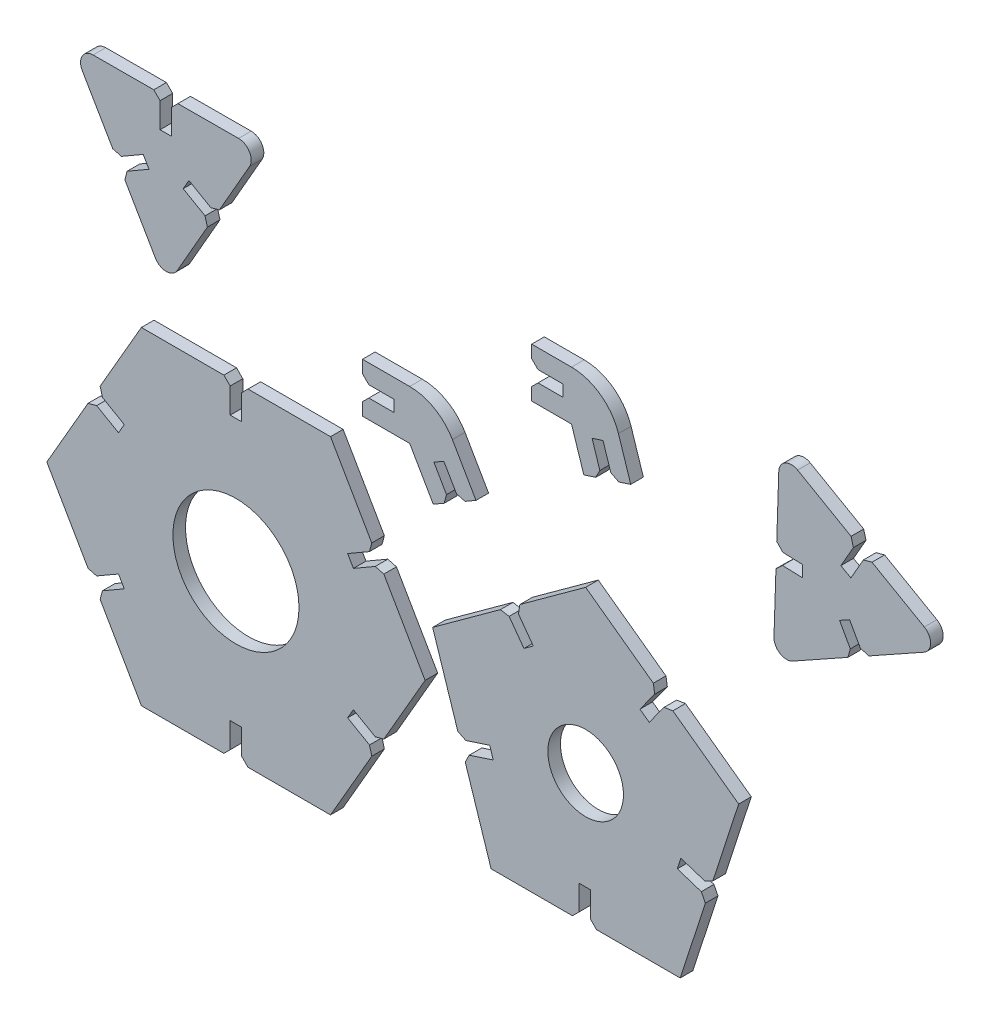
from build123d import *

# Parameters (mm, degrees)
SALIENTE_EXTRUIR1_DEPTH = 4
CHAFL_N1_SIZE           = 2
SALIENTE_EXTRUIR2_DEPTH = 4
CHAFL_N2_SIZE           = 2
SALIENTE_EXTRUIR3_DEPTH = 4
CHAFL_N3_SIZE           = 2
REDONDEO1_R             = 15.65
SALIENTE_EXTRUIR4_DEPTH = 4
REDONDEO2_R             = 15.65
CHAFL_N4_SIZE           = 2
CROQUIS5_R              = 20
CROQUIS5_R_2            = 12
CORTAR_EXTRUIR1_DEPTH   = 4
SALIENTE_EXTRUIR6_DEPTH = 4
REDONDEO4_R             = 4
SALIENTE_EXTRUIR7_DEPTH = 4
REDONDEO5_R             = 4
CHAFL_N5_SIZE           = 2
CHAFL_N5_SIZE2          = 1.993496113
CHAFL_N5_EDGE_2_SIZE    = 2
CHAFL_N5_EDGE_2_SIZE2   = 2.006567963
CHAFL_N5_EDGE_3_SIZE    = 1.993496113
CHAFL_N5_EDGE_3_SIZE2   = 2
CHAFL_N5_EDGE_4_SIZE    = 2.006567963
CHAFL_N5_EDGE_4_SIZE2   = 2
CHAFL_N5_EDGE_5_SIZE    = 1.993496113
CHAFL_N5_EDGE_5_SIZE2   = 2
CHAFL_N5_EDGE_6_SIZE    = 2
CHAFL_N5_EDGE_6_SIZE2   = 2.006567963
CHAFL_N6_SIZE           = 2


with BuildPart() as part:
    # Croquis1 → Saliente-Extruir1 (new body)
    with BuildSketch(Plane.XY):
        Polygon((-22.498762614, 34.692740635), (-16.620910091, 26.602570691), (-19.57382212, 24.45715452), (-25.451674643, 32.547324464), (-48.541019662, 15.771933364), (-39.947257049, -10.676948355), (-30.436691886, -7.586778411), (-29.308779857, -11.058134695), (-38.819345019, -14.148304639), (-30, -41.291457614), (-2.19, -41.291457614), (-2.19, -31.291457614), (1.46, -31.291457614), (1.46, -41.291457614), (30, -41.291457614), (38.593762614, -14.842575896), (29.083197451, -11.752405952), (30.21110948, -8.281049668), (39.721674643, -11.371219611), (48.541019662, 15.771933364), (26.042257049, 32.11824123), (20.164404526, 24.028071286), (17.211492497, 26.173487457), (23.089345019, 34.263657401), (0, 51.039048501), align=None)
    extrude(amount=SALIENTE_EXTRUIR1_DEPTH)

    # Chaflán1
    chafl_n1_edges = [part.edges().sort_by_distance(p)[0] for p in [
        (23.089345019, 34.263657401, 2),
        (26.042257049, 32.11824123, 2),
        (39.721674643, -11.371219611, 2),
        (38.593762614, -14.842575896, 2),
        (1.46, -41.291457614, 2),
        (-2.19, -41.291457614, 2),
        (-38.819345019, -14.148304639, 2),
        (-39.947257049, -10.676948355, 2),
        (-25.451674643, 32.547324464, 2),
        (-22.498762614, 34.692740635, 2),
    ]]
    chamfer(chafl_n1_edges, length=CHAFL_N1_SIZE)


with BuildPart() as body_2:
    # Croquis2 → Saliente-Extruir2 (new body)
    with BuildSketch(Plane.XY):
        Polygon((-50.935771969, 0), (-65.023271969, 24.400265752), (-73.683526006, 19.400265752), (-75.508526006, 22.561258475), (-66.848271969, 27.561258475), (-80.935771969, 51.961524227), (-109.110771969, 51.961524227), (-109.110771969, 41.961524227), (-112.760771969, 41.961524227), (-112.760771969, 51.961524227), (-140.935771969, 51.961524227), (-155.023271969, 27.561258475), (-146.363017931, 22.561258475), (-148.188017931, 19.400265752), (-156.848271969, 24.400265752), (-170.935771969, 0), (-156.848271969, -24.400265752), (-148.188017931, -19.400265752), (-146.363017931, -22.561258475), (-155.023271969, -27.561258475), (-140.935771969, -51.961524227), (-112.760771969, -51.961524227), (-112.760771969, -41.961524227), (-109.110771969, -41.961524227), (-109.110771969, -51.961524227), (-80.935771969, -51.961524227), (-66.848271969, -27.561258475), (-75.508526006, -22.561258475), (-73.683526006, -19.400265752), (-65.023271969, -24.400265752), align=None)
    extrude(amount=SALIENTE_EXTRUIR2_DEPTH)

    # Chaflán2
    chafl_n2_edges = [body_2.edges().sort_by_distance(p)[0] for p in [
        (-65.023271969, -24.400265752, 2),
        (-66.848271969, -27.561258475, 2),
        (-109.110771969, -51.961524227, 2),
        (-112.760771969, -51.961524227, 2),
        (-155.023271969, -27.561258475, 2),
        (-156.848271969, -24.400265752, 2),
        (-156.848271969, 24.400265752, 2),
        (-155.023271969, 27.561258475, 2),
        (-112.760771969, 51.961524227, 2),
        (-109.110771969, 51.961524227, 2),
        (-66.848271969, 27.561258475, 2),
        (-65.023271969, 24.400265752, 2),
    ]]
    chamfer(chafl_n2_edges, length=CHAFL_N2_SIZE)


with BuildPart() as body_3:
    # Croquis3 → Saliente-Extruir3 (new body)
    with BuildSketch(Plane.XY):
        Polygon((-70.786284867, 78.305161206), (-46.786284867, 78.305161206), (-34.786284867, 57.520551515), (-39.98243729, 54.520551515), (-44.98243729, 63.180805553), (-48.143430014, 61.355805553), (-43.143430014, 52.695551515), (-48.339582437, 49.695551515), (-55.82181658, 62.655161206), (-70.786284867, 62.655161206), (-70.786284867, 68.655161206), (-60.786284867, 68.655161206), (-60.786284867, 72.305161206), (-70.786284867, 72.305161206), align=None)
    extrude(amount=SALIENTE_EXTRUIR3_DEPTH)

    # Chaflán3
    chafl_n3_edges = [body_3.edges().sort_by_distance(p)[0] for p in [
        (-39.98243729, 54.520551515, 2),
        (-43.143430014, 52.695551515, 2),
        (-70.786284867, 68.655161206, 2),
        (-70.786284867, 72.305161206, 2),
    ]]
    chamfer(chafl_n3_edges, length=CHAFL_N3_SIZE)

    # Redondeo1
    redondeo1_edges = [body_3.edges().sort_by_distance(p)[0] for p in [
        (-46.786284867, 78.305161206, 2),
    ]]
    fillet(redondeo1_edges, radius=REDONDEO1_R)


with BuildPart() as body_4:
    # Croquis4 → Saliente-Extruir4 (new body)
    with BuildSketch(Plane.XY):
        Polygon((-17.115231159, 109.292158512), (6.884768841, 109.292158512), (14.301176706, 86.466802121), (8.594837608, 84.612700155), (5.504667664, 94.123265318), (2.03331138, 92.995353288), (5.123481324, 83.484788125), (-0.582857774, 81.630686159), (-4.485621722, 93.642158512), (-17.115231159, 93.642158512), (-17.115231159, 99.642158512), (-7.115231159, 99.642158512), (-7.115231159, 103.292158512), (-17.115231159, 103.292158512), align=None)
    extrude(amount=SALIENTE_EXTRUIR4_DEPTH)

    # Redondeo2
    redondeo2_edges = [body_4.edges().sort_by_distance(p)[0] for p in [
        (6.884768841, 109.292158512, 2),
    ]]
    fillet(redondeo2_edges, radius=REDONDEO2_R)

    # Chaflán4
    chafl_n4_edges = [body_4.edges().sort_by_distance(p)[0] for p in [
        (8.594837608, 84.612700155, 2),
        (5.123481324, 83.484788125, 2),
        (-17.115231159, 99.642158512, 2),
        (-17.115231159, 103.292158512, 2),
    ]]
    chamfer(chafl_n4_edges, length=CHAFL_N4_SIZE)


with BuildPart() as cortar_extruir1_tool:
    # Croquis5 → Cortar-Extruir1 (new body)
    with BuildSketch(Plane.XY.offset(4)):
        with Locations((-110.935771969, 0)):
            Circle(CROQUIS5_R)
        Circle(CROQUIS5_R_2)
    extrude(amount=-CORTAR_EXTRUIR1_DEPTH)


with BuildPart() as part_1:
    add(part.part)

    # Cortar-Extruir1: cut by cortar_extruir1_tool
    add(cortar_extruir1_tool.part, mode=Mode.SUBTRACT)


with BuildPart() as body_2_1:
    add(body_2.part)

    # Cortar-Extruir1: cut by cortar_extruir1_tool
    add(cortar_extruir1_tool.part, mode=Mode.SUBTRACT)


with BuildPart() as body_5:
    # Croquis8 → Saliente-Extruir6 (new body)
    with BuildSketch(Plane.XY):
        Polygon((-163.180597318, 119.138873384), (-149.013359447, 94.784644314), (-140.353105409, 99.784644314), (-138.528105409, 96.62365159), (-147.178029607, 91.629615526), (-133.010791736, 67.275386456), (-119.003029607, 91.721688889), (-127.663283645, 96.721688889), (-125.838283645, 99.882681613), (-117.188359447, 94.888645548), (-103.180597318, 119.334947981), (-131.355597318, 119.242874618), (-131.355597318, 109.242874618), (-135.005597318, 109.242874618), (-135.005597318, 119.230946747), align=None)
    extrude(amount=SALIENTE_EXTRUIR6_DEPTH)

    # Redondeo4
    redondeo4_edges = [body_5.edges().sort_by_distance(p)[0] for p in [
        (-163.180597318, 119.138873384, 2),
        (-103.180597318, 119.334947981, 2),
        (-133.010791736, 67.275386456, 2),
    ]]
    fillet(redondeo4_edges, radius=REDONDEO4_R)

    # Chaflán5
    chafl_n5_edges = [body_5.edges().sort_by_distance(p)[0] for p in [
        (-147.178029607, 91.629615526, 2),
    ]]
    chafl_n5_side = [body_5.faces().sort_by_distance(p)[0] for p in [
        (-142.853067508, 94.126633558, 2),
    ]]
    chamfer(chafl_n5_edges, length=CHAFL_N5_SIZE, length2=CHAFL_N5_SIZE2, reference=chafl_n5_side[0])

    # Chaflán5 edge 2
    chafl_n5_edge_2_edges = [body_5.edges().sort_by_distance(p)[0] for p in [
        (-149.013359447, 94.784644314, 2),
    ]]
    chafl_n5_edge_2_side = [body_5.faces().sort_by_distance(p)[0] for p in [
        (-154.355133146, 103.967435023, 2),
    ]]
    chamfer(chafl_n5_edge_2_edges, length=CHAFL_N5_EDGE_2_SIZE, length2=CHAFL_N5_EDGE_2_SIZE2, reference=chafl_n5_edge_2_side[0])

    # Chaflán5 edge 3
    chafl_n5_edge_3_edges = [body_5.edges().sort_by_distance(p)[0] for p in [
        (-135.005597318, 119.230946747, 2),
    ]]
    chafl_n5_edge_3_side = [body_5.faces().sort_by_distance(p)[0] for p in [
        (-145.6290142, 119.196230377, 2),
    ]]
    chamfer(chafl_n5_edge_3_edges, length=CHAFL_N5_EDGE_3_SIZE, length2=CHAFL_N5_EDGE_3_SIZE2, reference=chafl_n5_edge_3_side[0])

    # Chaflán5 edge 4
    chafl_n5_edge_4_edges = [body_5.edges().sort_by_distance(p)[0] for p in [
        (-131.355597318, 119.242874618, 2),
    ]]
    chafl_n5_edge_4_side = [body_5.faces().sort_by_distance(p)[0] for p in [
        (-131.355597318, 114.242874618, 2),
    ]]
    chamfer(chafl_n5_edge_4_edges, length=CHAFL_N5_EDGE_4_SIZE, length2=CHAFL_N5_EDGE_4_SIZE2, reference=chafl_n5_edge_4_side[0])

    # Chaflán5 edge 5
    chafl_n5_edge_5_edges = [body_5.edges().sort_by_distance(p)[0] for p in [
        (-117.188359447, 94.888645548, 2),
    ]]
    chafl_n5_edge_5_side = [body_5.faces().sort_by_distance(p)[0] for p in [
        (-111.906716264, 104.106152628, 2),
    ]]
    chamfer(chafl_n5_edge_5_edges, length=CHAFL_N5_EDGE_5_SIZE, length2=CHAFL_N5_EDGE_5_SIZE2, reference=chafl_n5_edge_5_side[0])

    # Chaflán5 edge 6
    chafl_n5_edge_6_edges = [body_5.edges().sort_by_distance(p)[0] for p in [
        (-119.003029607, 91.721688889, 2),
    ]]
    chafl_n5_edge_6_side = [body_5.faces().sort_by_distance(p)[0] for p in [
        (-124.28467279, 82.504181809, 2),
    ]]
    chamfer(chafl_n5_edge_6_edges, length=CHAFL_N5_EDGE_6_SIZE, length2=CHAFL_N5_EDGE_6_SIZE2, reference=chafl_n5_edge_6_side[0])


with BuildPart() as body_6:
    # Croquis7 → Saliente-Extruir7 (new body)
    with BuildSketch(Plane.XY):
        Polygon((61.477596493, 120.158850294), (60.550315351, 91.979032037), (68.845638112, 91.706067311), (68.725596697, 88.05804181), (60.430273936, 88.331006536), (59.502992794, 60.151188278), (84.932843055, 74.360403009), (80.538692496, 82.224496335), (83.725020717, 84.004893051), (88.119171276, 76.140799725), (113.549021536, 90.350014456), (89.097148193, 104.347746952), (84.129008887, 95.669176111), (80.96133053, 97.482546958), (85.929469836, 106.161117799), align=None)
    extrude(amount=SALIENTE_EXTRUIR7_DEPTH)

    # Redondeo5
    redondeo5_edges = [body_6.edges().sort_by_distance(p)[0] for p in [
        (113.549021536, 90.350014456, 2),
        (59.502992794, 60.151188278, 2),
        (61.477596493, 120.158850294, 2),
    ]]
    fillet(redondeo5_edges, radius=REDONDEO5_R)

    # Chaflán6
    chafl_n6_edges = [body_6.edges().sort_by_distance(p)[0] for p in [
        (85.929469836, 106.161117799, 2),
        (89.097148193, 104.347746952, 2),
        (88.119171276, 76.140799725, 2),
        (84.932843055, 74.360403009, 2),
        (60.430273936, 88.331006536, 2),
        (60.550315351, 91.979032037, 2),
    ]]
    chamfer(chafl_n6_edges, length=CHAFL_N6_SIZE)


solid = Compound([body_3.part, body_4.part, part_1.part, body_2_1.part, body_5.part, body_6.part])
